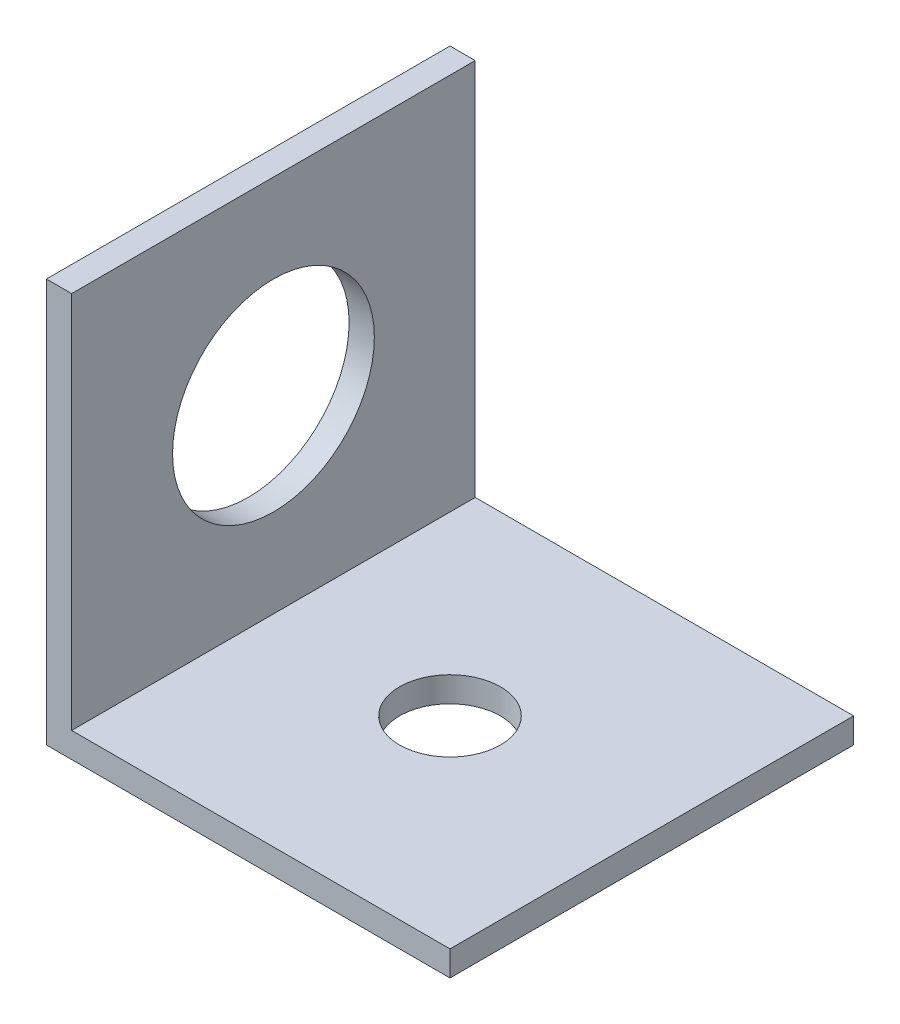
from build123d import *

# Parameters (mm, degrees)
BOSS_EXTRUDE1_DEPTH = 25.4
SKETCH2_R           = 3.175
CUT_EXTRUDE1_DEPTH  = 25.4
SKETCH3_R           = 6.35
CUT_EXTRUDE2_DEPTH  = 25.4


with BuildPart() as part:
    # Sketch1 → Boss-Extrude1 (new body)
    with BuildSketch(Plane.XY):
        Polygon((0, 0), (0, 25.4), (1.5875, 25.4), (1.5875, 1.5875), (25.4, 1.5875), (25.4, 0), align=None)
    extrude(amount=BOSS_EXTRUDE1_DEPTH)

    # Sketch2 → Cut-Extrude1 (cut)
    with BuildSketch(Plane(origin=(0, 1.5875, 0), x_dir=(1, 0, 0), z_dir=(0, 1, 0))):
        with Locations((12.7, -12.7)):
            Circle(SKETCH2_R)
    extrude(amount=-CUT_EXTRUDE1_DEPTH, mode=Mode.SUBTRACT)

    # Sketch3 → Cut-Extrude2 (cut)
    with BuildSketch(Plane(origin=(1.5875, 0, 0), x_dir=(0, 0, -1), z_dir=(1, 0, 0))):
        with Locations((-12.7, 13.49375)):
            Circle(SKETCH3_R)
    extrude(amount=-CUT_EXTRUDE2_DEPTH, mode=Mode.SUBTRACT)


solid = part.part
